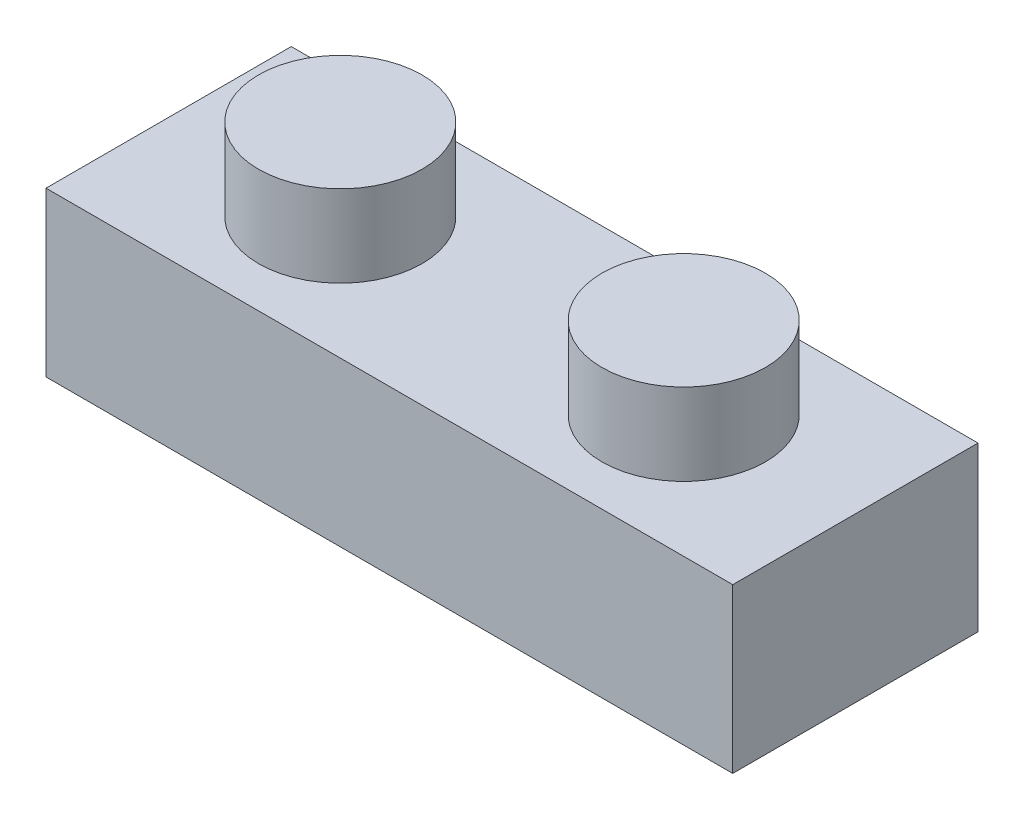
from build123d import *

# Parameters (mm, degrees)
SKETCH_1_W      = 42
SKETCH_1_H      = 15
EXTRUDE_1_DEPTH = 10
SKETCH_2_R      = 5
EXTRUDE_2_DEPTH = 5


with BuildPart() as part:
    # 草图1 → 凸台-拉伸1 (new body)
    with BuildSketch(Plane(origin=(0, 0, 0), x_dir=(1, 0, 0), z_dir=(0, 1, 0))):
        with Locations((21, -7.5)):
            Rectangle(SKETCH_1_W, SKETCH_1_H)
    extrude(amount=EXTRUDE_1_DEPTH)

    # 草图2 → 凸台-拉伸2 (add)
    with BuildSketch(Plane(origin=(0, 10, 0), x_dir=(1, 0, 0), z_dir=(0, 1, 0))):
        with Locations((31.5, -7.5)):
            Circle(SKETCH_2_R)
        with Locations((10.5, -7.5)):
            Circle(SKETCH_2_R)
    extrude(amount=EXTRUDE_2_DEPTH)


solid = part.part
